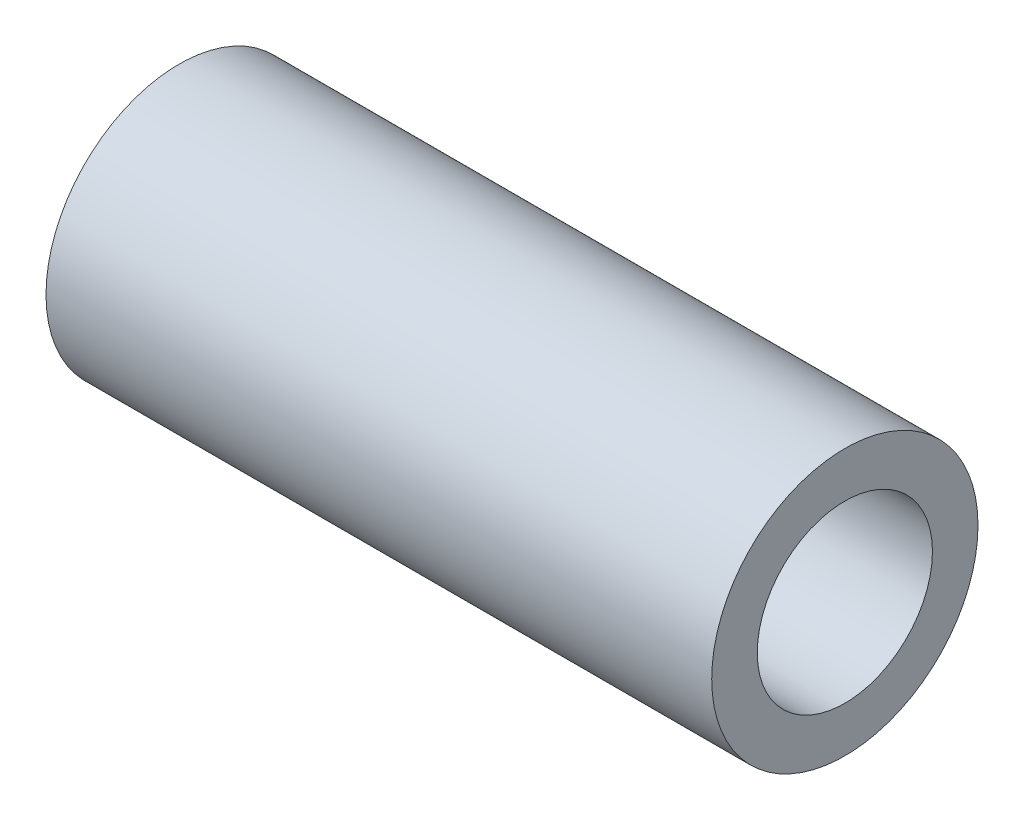
from build123d import *

# Parameters (mm, degrees)
SKETCH1_R           = 24.13
SKETCH1_R_2         = 15.875
BOSS_EXTRUDE1_DEPTH = 120.65


with BuildPart() as part:
    # Sketch1 → Boss-Extrude1 (new body)
    with BuildSketch(Plane(origin=(0, 0, 0), x_dir=(0, 0, -1), z_dir=(1, 0, 0))):
        Circle(SKETCH1_R)
        Circle(SKETCH1_R_2, mode=Mode.SUBTRACT)
    extrude(amount=BOSS_EXTRUDE1_DEPTH)


solid = part.part
